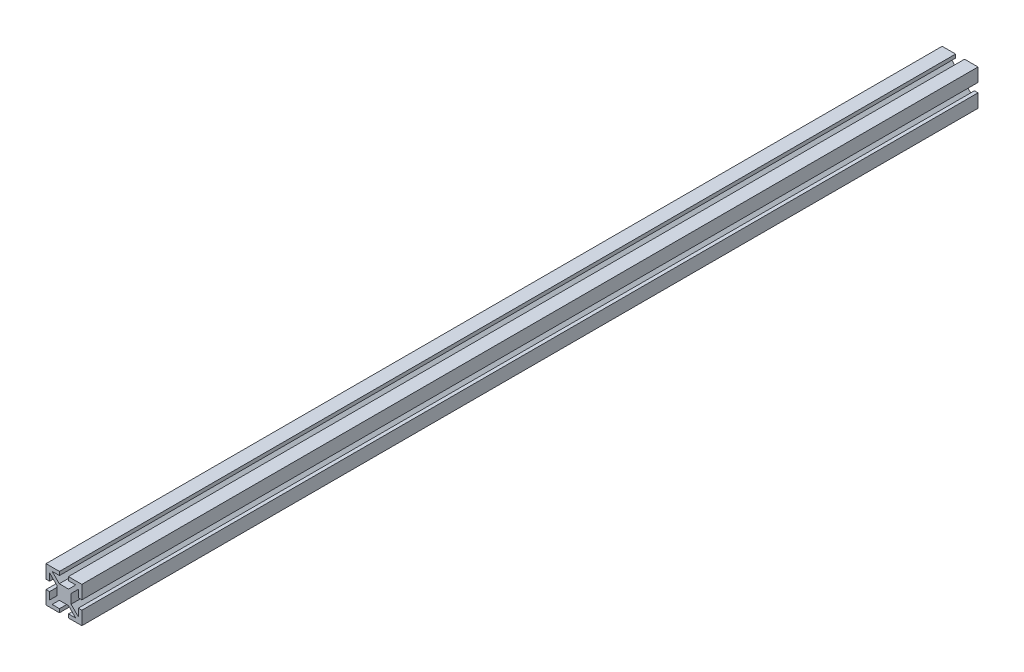
from build123d import *

# Parameters (mm, degrees)
BOSS_EXTRUDE1_DEPTH = 250
SKETCH2_R           = 2.5
CUT_EXTRUDE1_DEPTH  = 10


with BuildPart() as part:
    # Sketch1 → Boss-Extrude1 (new body, symmetric)
    with BuildSketch(Plane.XY):
        Polygon((-2.585786438, 4), (2.585786438, 4), (6.585786438, 8), (2.5, 8), (2.5, 10), (10, 10), (10, 2.5), (8, 2.5), (8, 6.585786438), (4, 2.585786438), (4, -2.585786438), (8, -6.585786438), (8, -2.5), (10, -2.5), (10, -10), (2.5, -10), (2.5, -8), (6.585786438, -8), (2.585786438, -4), (-2.585786438, -4), (-6.585786438, -8), (-2.5, -8), (-2.5, -10), (-10, -10), (-10, -2.5), (-8, -2.5), (-8, -6.585786438), (-4, -2.585786438), (-4, 2.585786438), (-8, 6.585786438), (-8, 2.5), (-10, 2.5), (-10, 10), (-2.5, 10), (-2.5, 8), (-6.585786438, 8), align=None)
    extrude(amount=BOSS_EXTRUDE1_DEPTH, both=True)

    # Sketch2 → Cut-Extrude1 (cut)
    with BuildSketch(Plane(origin=(4, 0, 0), x_dir=(0, 0, -1), z_dir=(1, 0, 0))):
        with Locations((-240, 0)):
            Circle(SKETCH2_R)
        with Locations((-90, 0)):
            Circle(SKETCH2_R)
    extrude(amount=-CUT_EXTRUDE1_DEPTH, mode=Mode.SUBTRACT)


solid = part.part
